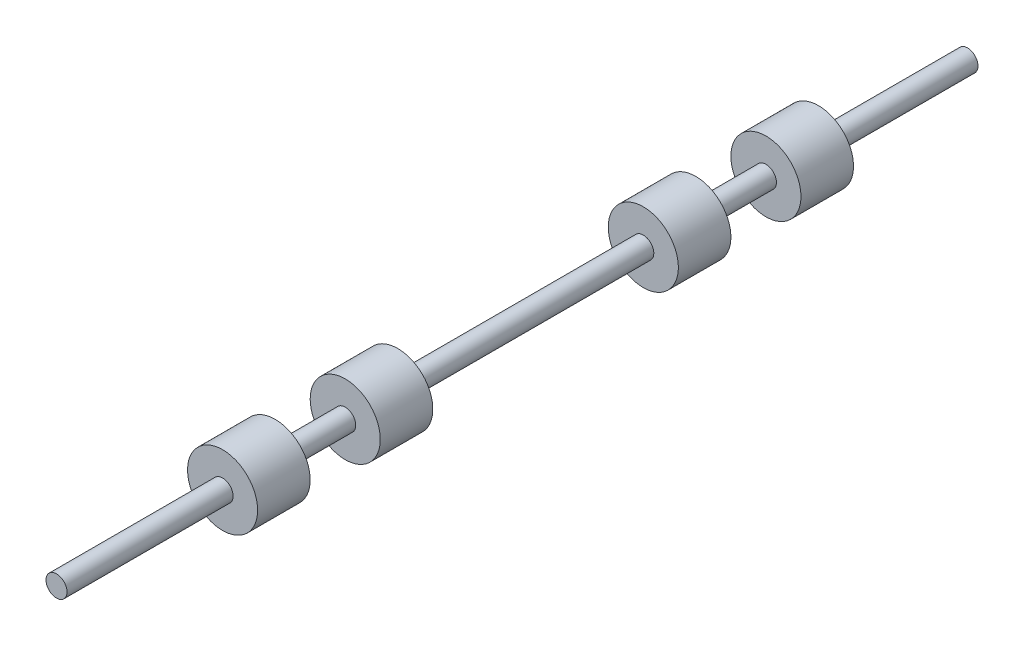
from build123d import *

# Parameters (mm, degrees)
SKETCH2_R           = 0.3
BOSS_EXTRUDE1_DEPTH = 26
SKETCH3_W           = 1
SKETCH3_H           = 1.5


with BuildPart() as part:
    # Sketch2 → Boss-Extrude1 (new body)
    with BuildSketch(Plane.XY):
        Circle(SKETCH2_R)
    extrude(amount=BOSS_EXTRUDE1_DEPTH)

    # Sketch3 → Revolve1 (revolve)
    with BuildSketch(Plane(origin=(0, 0, 0), x_dir=(1, 0, 0), z_dir=(0, 1, 0))):
        with Locations((0.5, -5.003)):
            Rectangle(SKETCH3_W, SKETCH3_H)
        with Locations((0.5, -8.503)):
            Rectangle(SKETCH3_W, SKETCH3_H)
        with Locations((0.5, -17.01)):
            Rectangle(SKETCH3_W, SKETCH3_H)
        with Locations((0.5, -20.51)):
            Rectangle(SKETCH3_W, SKETCH3_H)
    revolve(axis=Axis((0, 0, 0), (0, 0, 1)))


solid = part.part
